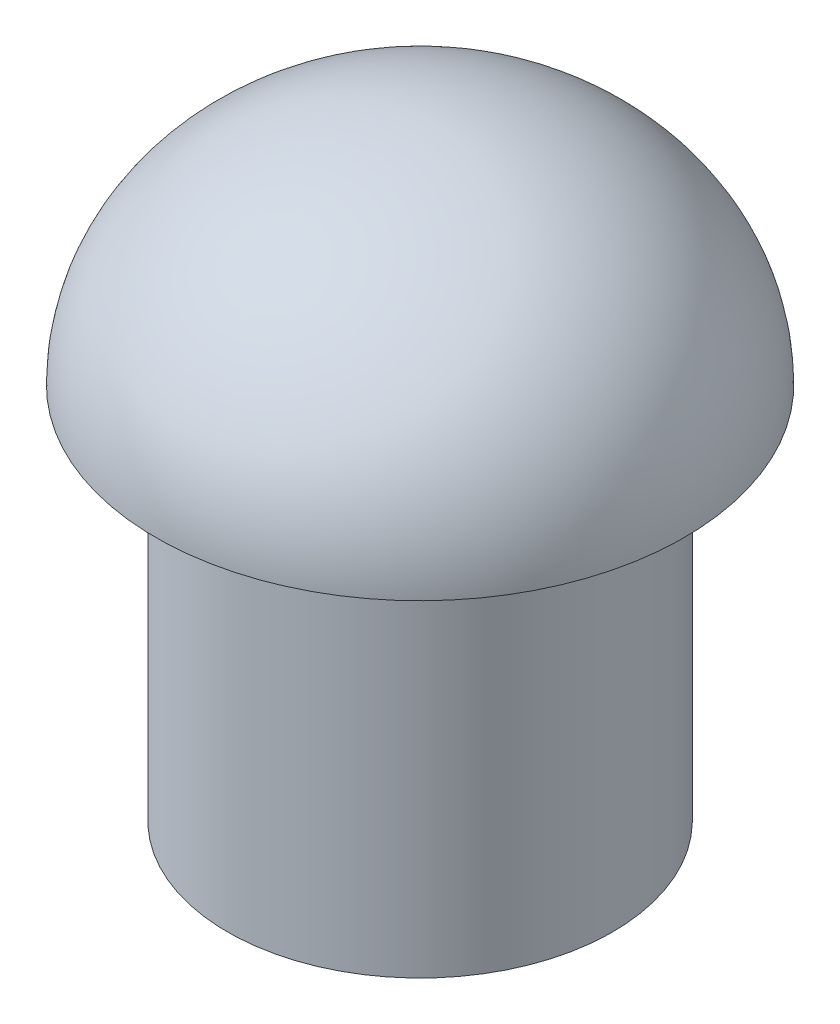
from build123d import *

# Parameters (mm, degrees)
SKETCH3_R           = 2.55
BOSS_EXTRUDE1_DEPTH = 5
SKETCH4_W           = 3.1
SKETCH4_H           = 3.1
CUT_EXTRUDE1_DEPTH  = 2


with BuildPart() as part:
    # Sketch1 → Revolve5 (revolve)
    with BuildSketch(Plane(origin=(0, 0, 0), x_dir=(0, 0, -1), z_dir=(1, 0, 0))):
        with BuildLine():
            Line((0, 3), (0, 0))
            Line((0, 0), (3.5, 0))
            add(Edge.make_bspline(
                [(3.5, 0), (3.5, 3), (0, 3)],
                knots=[3.141592654, 3.141592654, 3.141592654, 4.71238898, 4.71238898, 4.71238898], degree=2, weights=[1, 0.707106781, 1]))
        make_face()
    revolve(axis=Axis((0, 0, 0), (0, 1, 0)))

    # Sketch3 → Boss-Extrude1 (add)
    with BuildSketch(Plane.XZ):
        Circle(SKETCH3_R)
    extrude(amount=BOSS_EXTRUDE1_DEPTH)

    # Sketch4 → Cut-Extrude1 (cut)
    with BuildSketch(Plane.XZ.offset(5)):
        Rectangle(SKETCH4_W, SKETCH4_H)
    extrude(amount=-CUT_EXTRUDE1_DEPTH, mode=Mode.SUBTRACT)


solid = part.part
